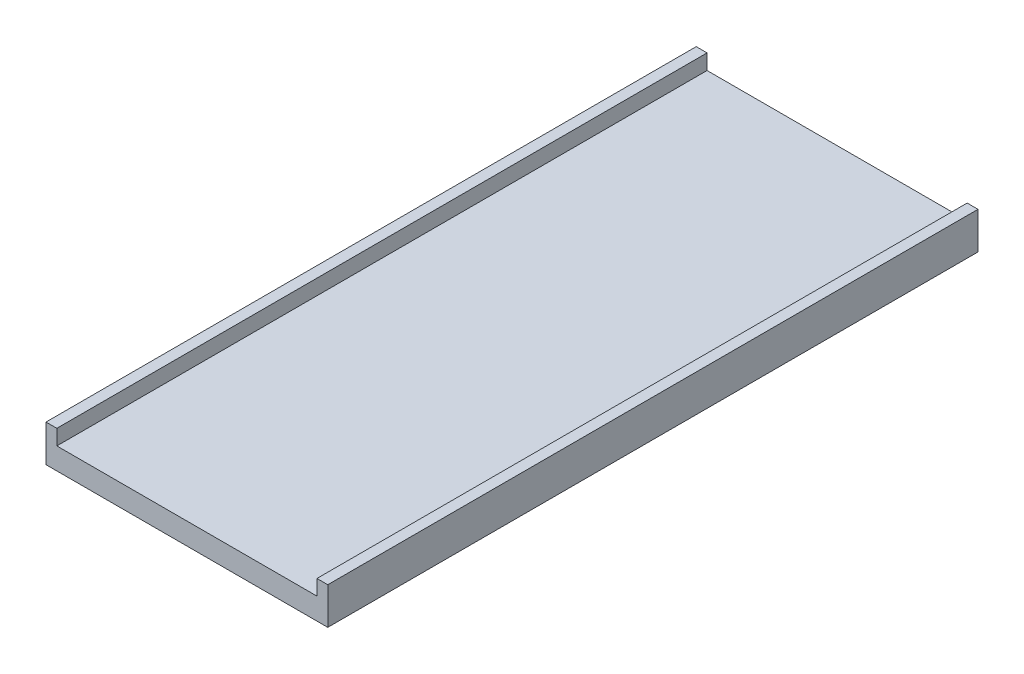
from build123d import *

# Parameters (mm, degrees)
BOSS_EXTRUDE1_DEPTH = 1500


with BuildPart() as part:
    # Sketch1 → Boss-Extrude1 (new body)
    with BuildSketch(Plane.XY):
        Polygon((0, 0), (25, 0), (25, -35.236081748), (625, -35.236081748), (625, 0), (650, 0), (650, -85.236081748), (0, -85.236081748), align=None)
    extrude(amount=BOSS_EXTRUDE1_DEPTH)


solid = part.part
